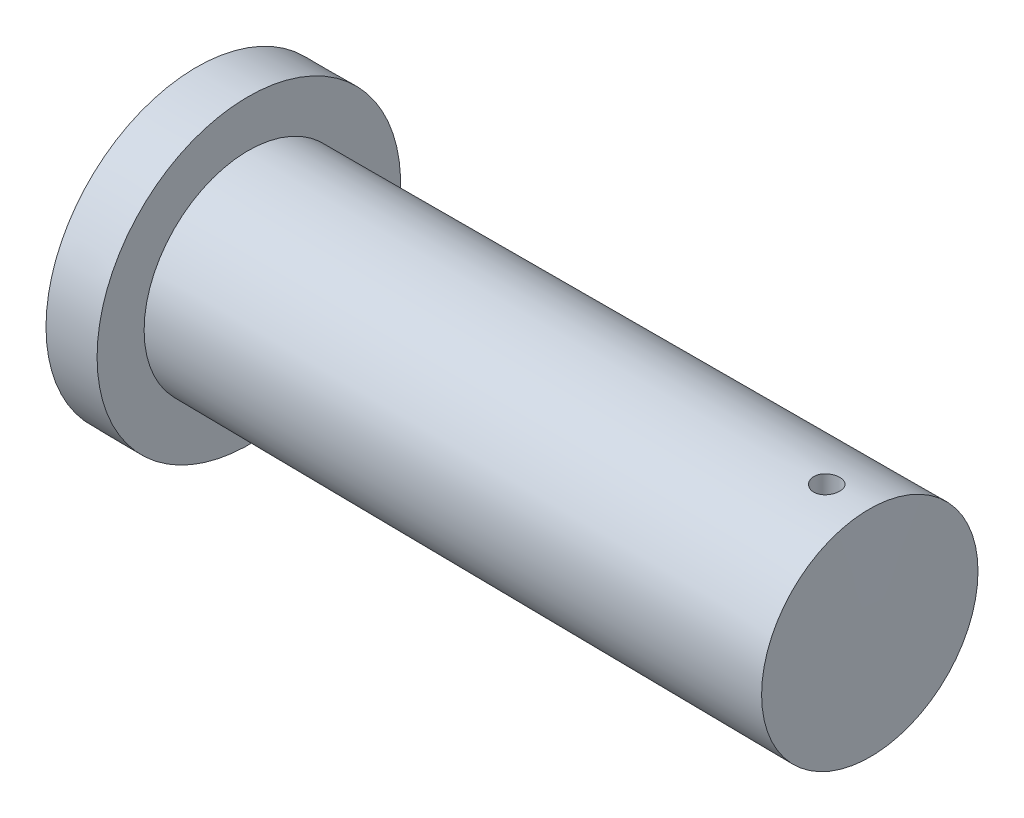
from build123d import *

# Parameters (mm, degrees)
SKETCH3_R               = 30
CUT_EXTRUDE1_DEPTH      = 1276.152304466
CUT_EXTRUDE1_DEPTH_BACK = 1276.152304466


with BuildPart() as part:
    # Sketch1 → Revolve1 (revolve)
    with BuildSketch(Plane(origin=(0, 0, 0), x_dir=(1, 0, 0), z_dir=(0, 1, 0)), mode=Mode.PRIVATE) as revolve1_sk:
        Polygon((-420.995670996, -76.298701299), (1149.004329004, -84.956709957), (1149.004329004, 165.043290043), (-301.594882448, 165.043290043), (-300.995670996, 273.701298701), (-420.995670996, 273.701298701), align=None)
    revolve(revolve1_sk.sketch.rotate(Axis((-420.995670996, 0, 76.298701299), (0.9999847946358453, 0, 0.0055145713438433585)), 180), axis=Axis((-420.995670996, 0, 76.298701299), (0.9999847946358453, 0, 0.0055145713438433585)))

    # Sketch3 → Cut-Extrude1 (cut, two sides)
    with BuildSketch(Plane(origin=(0, 0, 0), x_dir=(1, 0, 0), z_dir=(0, 1, 0))) as cut_extrude1_sk:
        with Locations(Location((1047.050081881, -84.394467438, 0), (0, 0, 123.159847216))):
            Circle(SKETCH3_R)
    extrude(amount=CUT_EXTRUDE1_DEPTH, mode=Mode.SUBTRACT)
    extrude(cut_extrude1_sk.sketch, amount=-CUT_EXTRUDE1_DEPTH_BACK, mode=Mode.SUBTRACT)


solid = part.part
